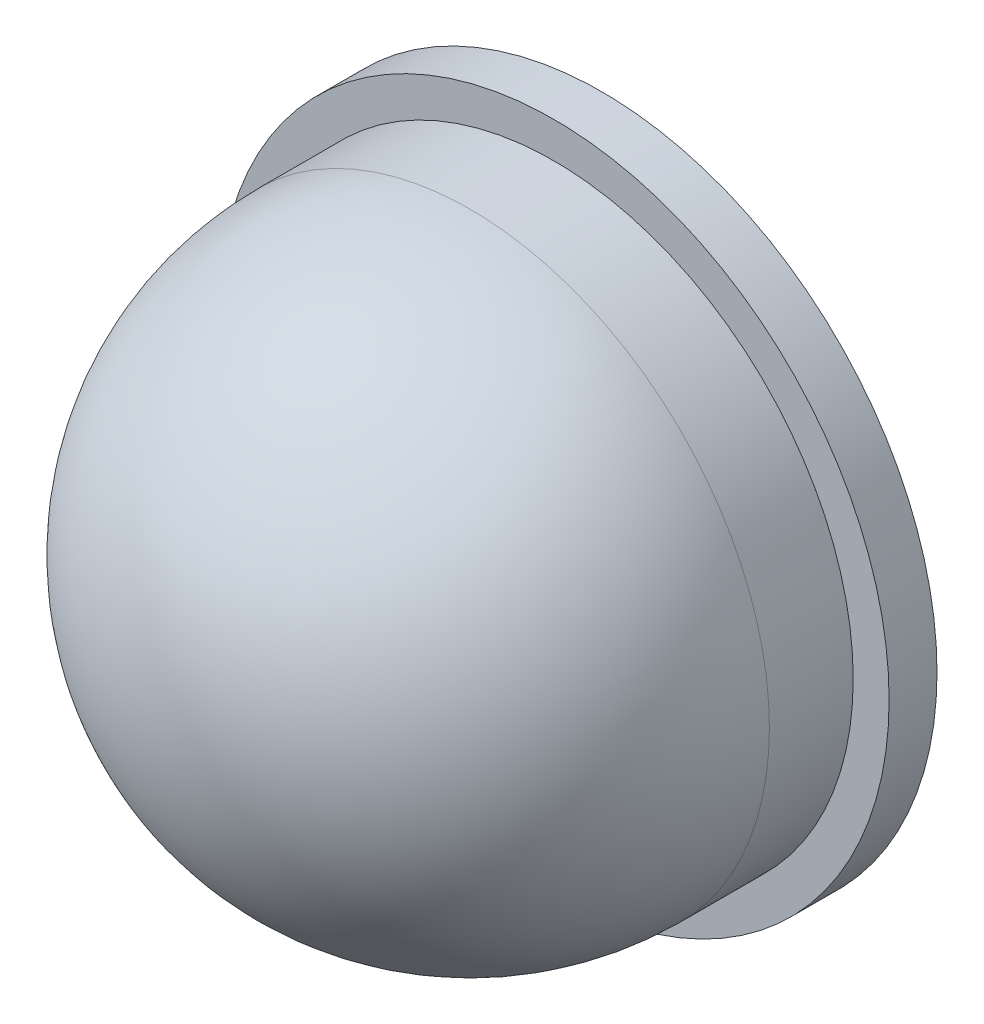
from build123d import *

# Parameters (mm, degrees)
SKETCH1_R           = 12.5
BOSS_EXTRUDE1_DEPTH = 16
FILLET1_R           = 12.5
SKETCH2_R           = 14
BOSS_EXTRUDE2_DEPTH = 2


with BuildPart() as part:
    # Sketch1 → Boss-Extrude1 (new body)
    with BuildSketch(Plane.XY):
        Circle(SKETCH1_R)
    extrude(amount=BOSS_EXTRUDE1_DEPTH)

    # Fillet1
    fillet1_edges = [part.edges().sort_by_distance(p)[0] for p in [
        (-12.5, 0, 16),
    ]]
    fillet(fillet1_edges, radius=FILLET1_R)

    # Sketch2 → Boss-Extrude2 (add)
    with BuildSketch(Plane(origin=(0, 0, 0), x_dir=(-1, 0, 0), z_dir=(0, 0, -1))):
        Circle(SKETCH2_R)
    extrude(amount=BOSS_EXTRUDE2_DEPTH)


solid = part.part
